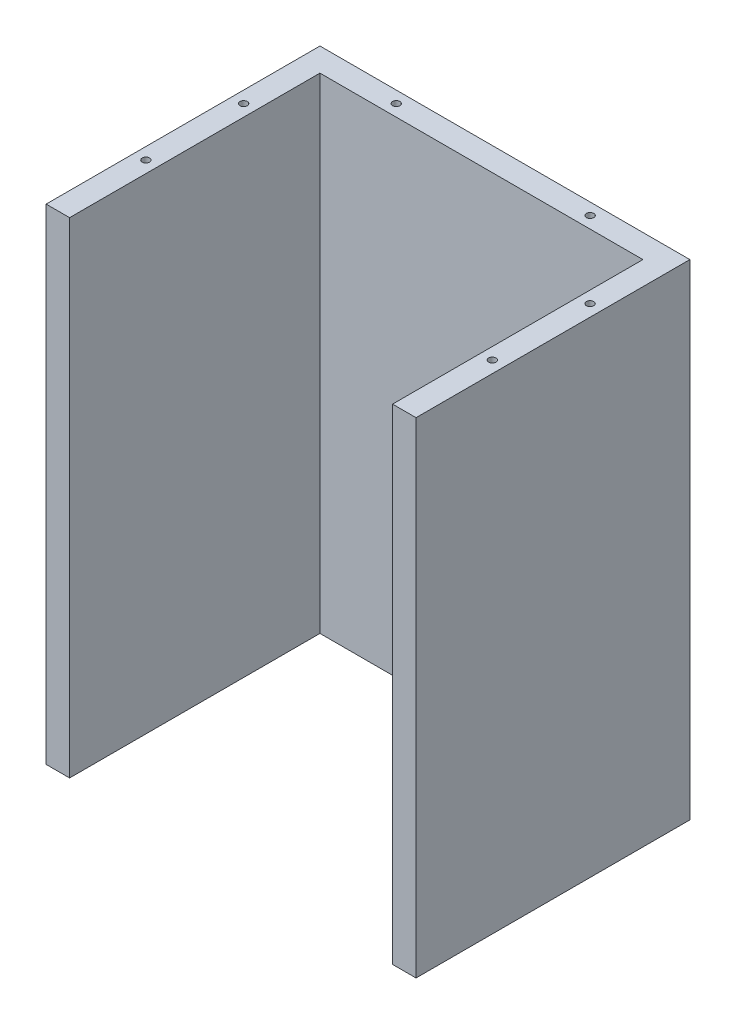
from build123d import *

# Parameters (mm, degrees)
SKETCH1_W                      = 180.086
SKETCH1_H                      = 165.1
BOSS_EXTRUDE1_DEPTH            = 3.302
M5_CLEARANCE_HOLE2_D           = 5.5
M5_CLEARANCE_HOLE2_DEPTH       = 3.302
FILLET1_R                      = 3.302
BOSS_EXTRUDE2_DEPTH            = 210
F_1_8_0_1250_DOWEL_HOLE1_D     = 3.175
F_1_8_0_1250_DOWEL_HOLE1_DEPTH = 25.4
F_1_8_0_1250_DOWEL_HOLE1_TIP   = 0.953866233
SKETCH25_W                     = 202.106165301
SKETCH25_H                     = 177.594943489
CUT_EXTRUDE1_DEPTH             = 213.3
SKETCH26_W                     = 189.404895816
SKETCH26_H                     = 174.029674862
CUT_EXTRUDE3_DEPTH             = 3.302


with BuildPart() as part:
    # Sketch1 → Boss-Extrude1 (new body)
    with BuildSketch(Plane(origin=(0, 0, 0), x_dir=(1, 0, 0), z_dir=(0, 1, 0))):
        Rectangle(SKETCH1_W, SKETCH1_H)
    extrude(amount=BOSS_EXTRUDE1_DEPTH)

    # M5 Clearance Hole2
    with Locations(Plane(origin=(0, 3.302, 0), x_dir=(1, 0, 0), z_dir=(0, 1, 0))):
        with Locations((51.943, -72.39), (-51.943, -72.39), (51.943, 72.39), (-51.943, 72.39)):
            Hole(M5_CLEARANCE_HOLE2_D / 2, depth=M5_CLEARANCE_HOLE2_DEPTH)

    # Fillet1
    fillet1_edges = [part.edges().sort_by_distance(p)[0] for p in [
        (90.043, 1.651, 82.55),
        (-90.043, 1.651, 82.55),
        (-90.043, 1.651, -82.55),
        (90.043, 1.651, -82.55),
    ]]
    fillet(fillet1_edges, radius=FILLET1_R)

    # Sketch12 → Boss-Extrude2 (add)
    with BuildSketch(Plane.XZ):
        Polygon((90.043, -59.25), (90.043, 59.25), (79.883, 59.25), (79.883, -49.09), (-59.883, -49.09), (-59.883, 59.25), (-70.043, 59.25), (-70.043, -59.25), align=None)
    extrude(amount=BOSS_EXTRUDE2_DEPTH)

    # 1/8 (0.1250) Dowel Hole1
    with Locations(Plane(origin=(0, -210, 0), x_dir=(-1, 0, 0), z_dir=(0, -1, 0))):
        with Locations((64.963, -21.15), (64.963, 21.15), (31.943, 54.17), (-51.943, 54.17), (-84.963, 21.15), (-84.963, -21.15)):
            Hole(F_1_8_0_1250_DOWEL_HOLE1_D / 2, depth=F_1_8_0_1250_DOWEL_HOLE1_DEPTH)
            with Locations((0, 0, -(F_1_8_0_1250_DOWEL_HOLE1_DEPTH + F_1_8_0_1250_DOWEL_HOLE1_TIP / 2))):  # 118° drill point
                Cone(0, F_1_8_0_1250_DOWEL_HOLE1_D / 2, F_1_8_0_1250_DOWEL_HOLE1_TIP, mode=Mode.SUBTRACT)


with BuildPart() as body_2:
    # Mirror1: mirrored copy
    add(part.part.mirror(Plane(origin=(0, -210, 0), x_dir=(0, 0, 1), z_dir=(0, -1, 0))))

    # Sketch26 → Cut-Extrude3 (cut)
    with BuildSketch(Plane.XZ.offset(423.302)):
        with Locations((0, -0.222829289)):
            Rectangle(SKETCH26_W, SKETCH26_H)
    extrude(amount=-CUT_EXTRUDE3_DEPTH, mode=Mode.SUBTRACT)


with BuildPart() as part_1:
    add(part.part)

    # Sketch25 → Cut-Extrude1 (cut)
    with BuildSketch(Plane(origin=(0, 3.302, 0), x_dir=(1, 0, 0), z_dir=(0, 1, 0))):
        with Locations((0.111414645, -1.559805025)):
            Rectangle(SKETCH25_W, SKETCH25_H)
    extrude(amount=-CUT_EXTRUDE1_DEPTH, mode=Mode.SUBTRACT)


solid = Compound([body_2.part, part_1.part])
